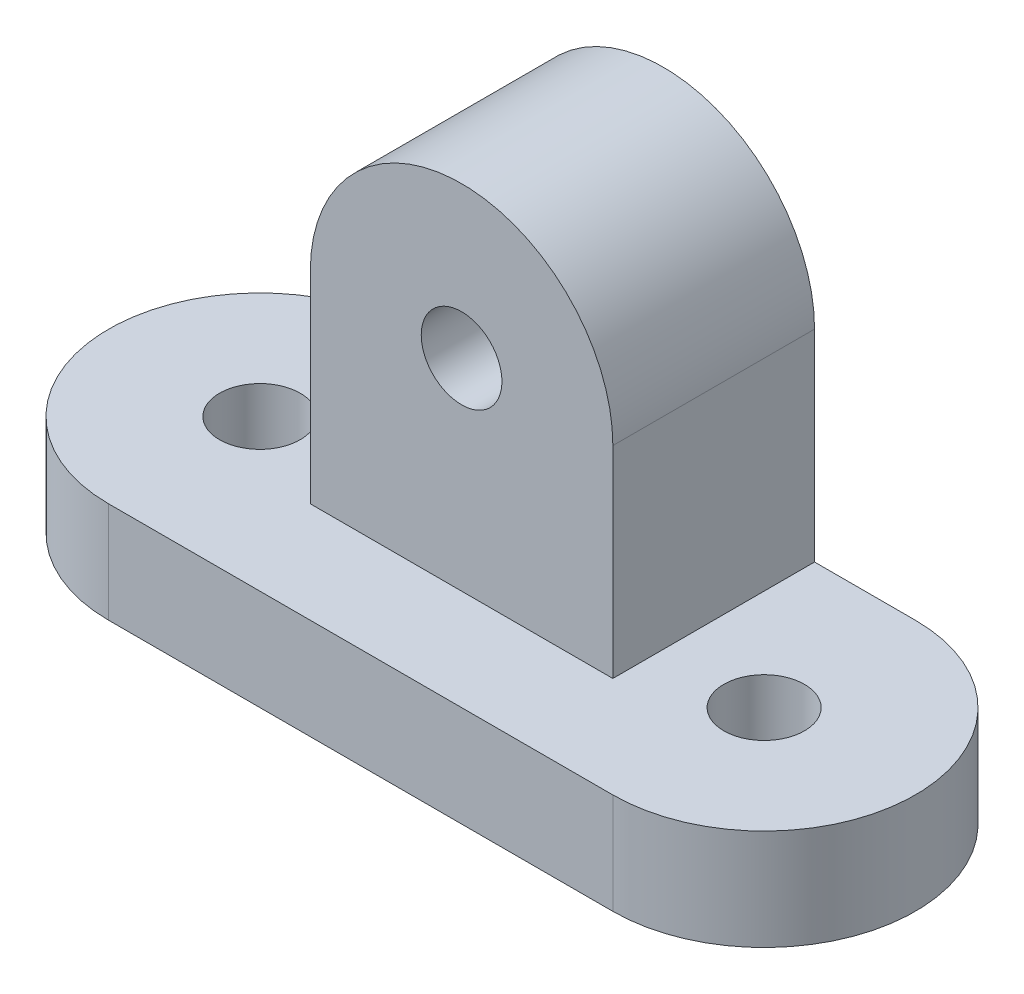
from build123d import *

# Parameters (mm, degrees)
SKETCH1_R           = 2
BOSS_EXTRUDE1_DEPTH = 5
SKETCH3_R           = 2
BOSS_EXTRUDE2_DEPTH = 10


with BuildPart() as part:
    # Sketch1 → Boss-Extrude1 (new body)
    with BuildSketch(Plane(origin=(0, 0, 0), x_dir=(1, 0, 0), z_dir=(0, 1, 0))):
        with BuildLine():
            Line((0, 0), (25, 0))
            ThreePointArc((25, 0), (32.5, 7.5), (25, 15))
            Line((25, 15), (0, 15))
            ThreePointArc((0, 15), (-7.5, 7.5), (0, 0))
        make_face()
        with Locations((0, 7.5)):
            Circle(SKETCH1_R, mode=Mode.SUBTRACT)
        with Locations((25, 7.5)):
            Circle(SKETCH1_R, mode=Mode.SUBTRACT)
    extrude(amount=BOSS_EXTRUDE1_DEPTH)

    # Sketch3 → Boss-Extrude2 (add)
    with BuildSketch(Plane(origin=(0, 0, -15), x_dir=(-1, 0, 0), z_dir=(0, 0, -1))):
        with BuildLine():
            Line((-20, 5), (-5, 5))
            Line((-5, 5), (-5, 15))
            ThreePointArc((-5, 15), (-12.5, 22.5), (-20, 15))
            Line((-20, 15), (-20, 5))
        make_face()
        with Locations((-12.5, 15)):
            Circle(SKETCH3_R, mode=Mode.SUBTRACT)
    extrude(amount=-BOSS_EXTRUDE2_DEPTH)


solid = part.part
